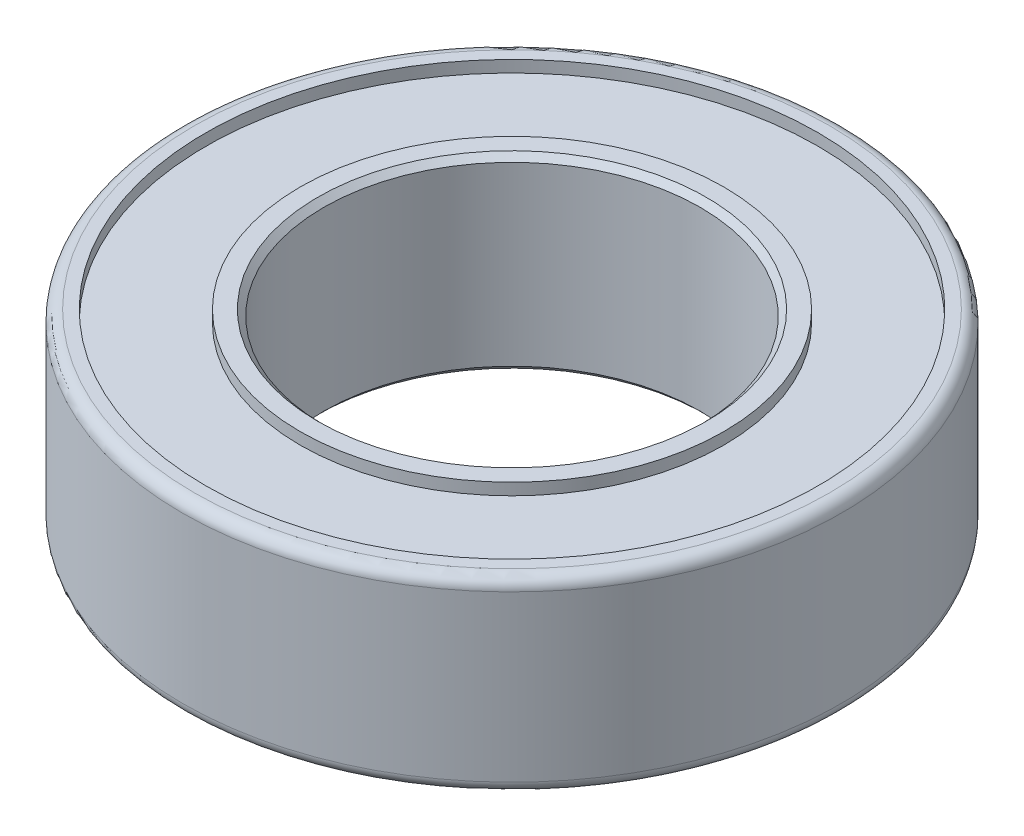
from build123d import *

# Parameters (mm, degrees)
SKETCH2_R           = 7
SKETCH2_R_2         = 4
BOSS_EXTRUDE1_DEPTH = 2
SKETCH3_R           = 6.5
SKETCH3_R_2         = 4.5
CUT_EXTRUDE1_DEPTH  = 0.25
FILLET1_R           = 0.25
CHAMFER1_SIZE       = 0.125


with BuildPart() as part:
    # Sketch2 → Boss-Extrude1 (new body, symmetric)
    with BuildSketch(Plane(origin=(0, 0, 0), x_dir=(1, 0, 0), z_dir=(0, 1, 0))):
        Circle(SKETCH2_R)
        Circle(SKETCH2_R_2, mode=Mode.SUBTRACT)
    extrude(amount=BOSS_EXTRUDE1_DEPTH, both=True)

    # Sketch3 → Cut-Extrude1 (cut)
    with BuildSketch(Plane(origin=(0, 2, 0), x_dir=(1, 0, 0), z_dir=(0, 1, 0))):
        Circle(SKETCH3_R)
        Circle(SKETCH3_R_2, mode=Mode.SUBTRACT)
    cut_extrude1 = extrude(amount=-CUT_EXTRUDE1_DEPTH, mode=Mode.SUBTRACT)

    # Mirror1: Cut-Extrude1 across plane
    add(cut_extrude1.mirror(Plane.ZX), mode=Mode.SUBTRACT)

    # Fillet1
    fillet1_edges = [part.edges().sort_by_distance(p)[0] for p in [
        (-7, -2, 0),
        (-7, 2, 0),
    ]]
    fillet(fillet1_edges, radius=FILLET1_R)

    # Chamfer1
    chamfer1_edges = [part.edges().sort_by_distance(p)[0] for p in [
        (-4, -2, 0),
        (-4, 2, 0),
    ]]
    chamfer(chamfer1_edges, length=CHAMFER1_SIZE)


solid = part.part
